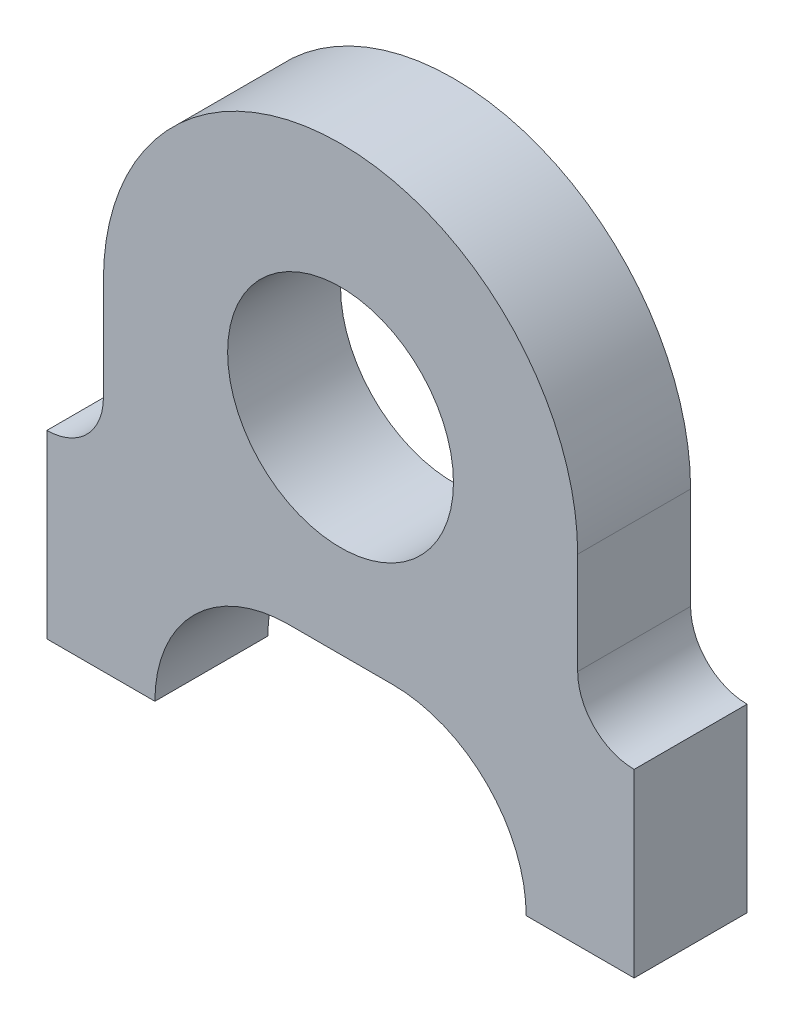
from build123d import *

# Parameters (mm, degrees)
SKETCH1_R           = 6.35
BOSS_EXTRUDE1_DEPTH = 6.35


with BuildPart() as part:
    # Sketch1 → Boss-Extrude1 (new body)
    with BuildSketch(Plane.XY):
        with BuildLine():
            Line((-13.335, 0), (-13.335, -5.715))
            ThreePointArc((-13.335, -5.715), (-14.26493597, -7.96006403), (-16.51, -8.89))
            Line((-16.51, -8.89), (-16.51, -19.05))
            Line((-16.51, -19.05), (-10.4394, -19.05))
            ThreePointArc((-10.4394, -19.05), (-8.242182532, -13.745447789), (-2.93763032, -11.54823032))
            Line((-2.93763032, -11.54823032), (2.93763032, -11.54823032))
            ThreePointArc((2.93763032, -11.54823032), (8.242182532, -13.745447789), (10.4394, -19.05))
            Line((10.4394, -19.05), (16.51, -19.05))
            Line((16.51, -19.05), (16.51, -8.89))
            ThreePointArc((16.51, -8.89), (14.26493597, -7.96006403), (13.335, -5.715))
            Line((13.335, -5.715), (13.335, 0))
            ThreePointArc((13.335, 0), (0, 13.335), (-13.335, 0))
        make_face()
        Circle(SKETCH1_R, mode=Mode.SUBTRACT)
    extrude(amount=BOSS_EXTRUDE1_DEPTH)

    # Sketch2 → Tap Drill for #6-32 Tap1 (revolve, cut)
    with BuildSketch(Plane(origin=(-13.4747, -19.05, 3.175), x_dir=(0, 0, -1), z_dir=(1, 0, 0))):
        Polygon((0, 0), (0, 8.43269403), (1.35255, 7.62), (1.35255, 0), align=None)
    tap_drill_for_6_32_tap1 = revolve(axis=Axis((-13.4747, -25.4, 3.175), (0, 1, 0)), mode=Mode.SUBTRACT)

    # Mirror1: Tap Drill for #6-32 Tap1 across plane
    add(tap_drill_for_6_32_tap1.mirror(Plane(origin=(0, 0, 0), x_dir=(0, 0, 1), z_dir=(1, 0, 0))), mode=Mode.SUBTRACT)


solid = part.part
